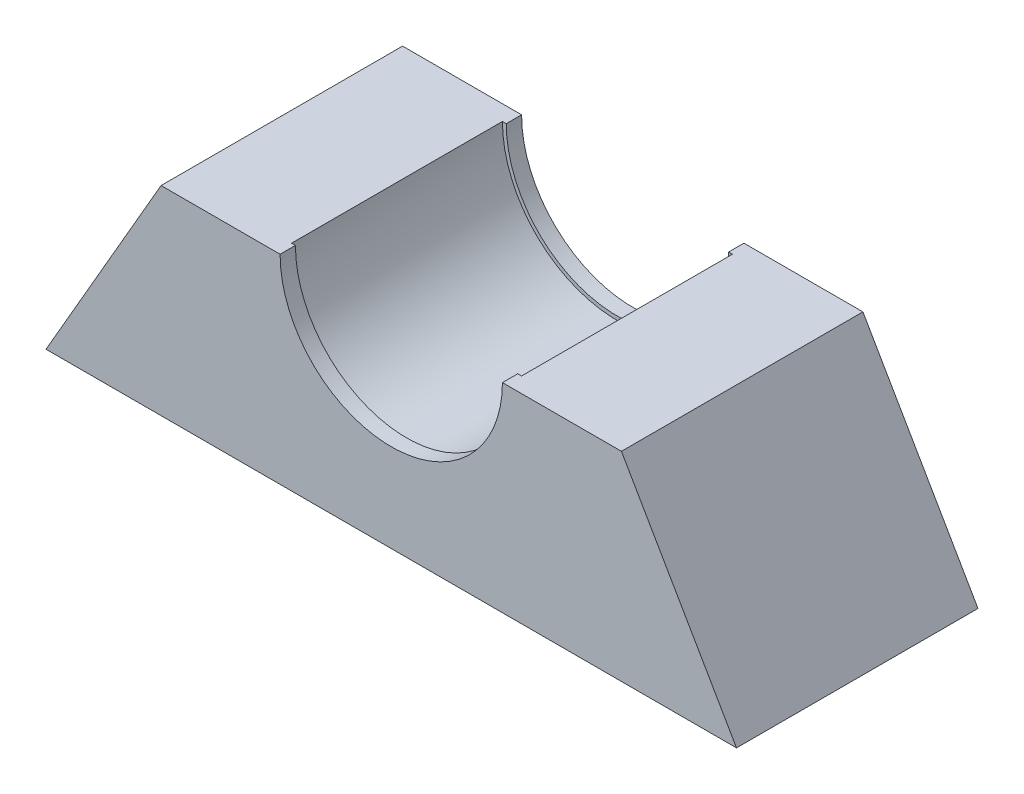
from build123d import *

# Parameters (mm, degrees)
BOSS_EXTRUDE1_DEPTH = 27.5
BOSS_EXTRUDE2_DEPTH = 2
BOSS_EXTRUDE3_DEPTH = 2


with BuildPart() as part:
    # Frame → Boss-Extrude1 (new body)
    with BuildSketch(Plane.XY):
        with BuildLine():
            Line((-45.033320997, -26), (45.033320997, -26))
            Line((45.033320997, -26), (30.022213998, 0))
            Line((30.022213998, 0), (18, 0))
            ThreePointArc((18, 0), (0, -18), (-18, 0))
            Line((-18, 0), (-30.022213998, 0))
            Line((-30.022213998, 0), (-45.033320997, -26))
        make_face()
        with BuildLine():
            ThreePointArc((-18, 0), (0, -18), (18, 0))
            Line((18, 0), (15, 0))
            ThreePointArc((15, 0), (0, -15), (-15, 0))
            Line((-15, 0), (-18, 0))
        make_face()
    extrude(amount=BOSS_EXTRUDE1_DEPTH)

    # lip → Boss-Extrude2 (add)
    with BuildSketch(Plane.XY.offset(27.5)):
        with BuildLine():
            Line((45.033320997, -26), (30.022213998, 0))
            Line((30.022213998, 0), (15, 0))
            ThreePointArc((15, 0), (0, -15), (-15, 0))
            Line((-15, 0), (-30.022213998, 0))
            Line((-30.022213998, 0), (-45.033320997, -26))
            Line((-45.033320997, -26), (45.033320997, -26))
        make_face()
        with BuildLine():
            ThreePointArc((14.5, 0), (0, -14.5), (-14.5, 0))
            Line((-14.5, 0), (-15, 0))
            ThreePointArc((-15, 0), (0, -15), (15, 0))
            Line((15, 0), (14.5, 0))
        make_face()
    extrude(amount=BOSS_EXTRUDE2_DEPTH)

    # lip2 → Boss-Extrude3 (add)
    with BuildSketch(Plane(origin=(0, 0, 0), x_dir=(-1, 0, 0), z_dir=(0, 0, -1))):
        with BuildLine():
            ThreePointArc((15, 0), (0, -15), (-15, 0))
            Line((-15, 0), (-30.022213998, 0))
            Line((-30.022213998, 0), (-45.033320997, -26))
            Line((-45.033320997, -26), (45.033320997, -26))
            Line((45.033320997, -26), (30.022213998, 0))
            Line((30.022213998, 0), (15, 0))
        make_face()
        with BuildLine():
            Line((-14.5, 0), (-15, 0))
            ThreePointArc((-15, 0), (0, -15), (15, 0))
            Line((15, 0), (14.5, 0))
            ThreePointArc((14.5, 0), (0, -14.5), (-14.5, 0))
        make_face()
    extrude(amount=BOSS_EXTRUDE3_DEPTH)


solid = part.part
